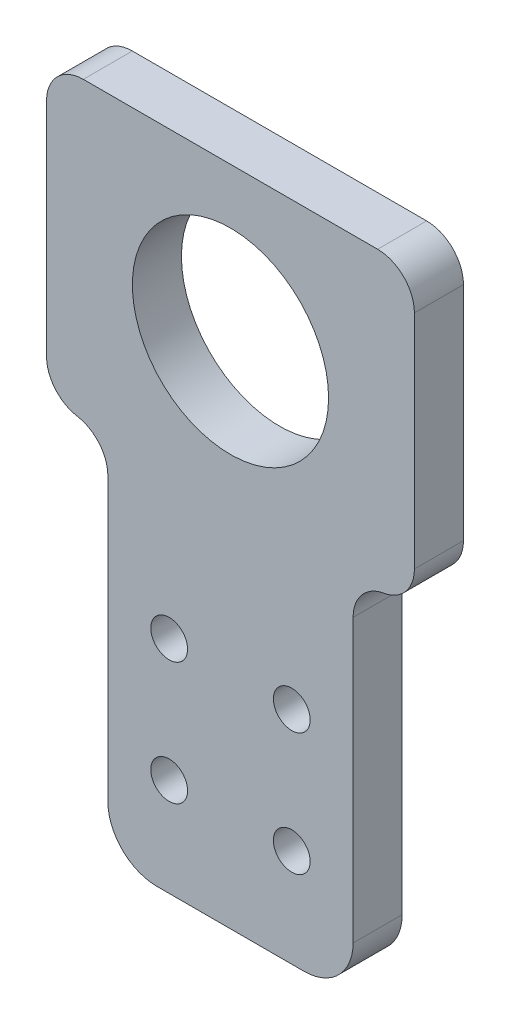
from build123d import *

# Parameters (mm, degrees)
SKETCH_1_W          = 20
SKETCH_1_H          = 30
SKETCH_1_R          = 1.5
EXTRUDE_1_DEPTH     = 4
SKETCH_2_W          = 30
SKETCH_2_H          = 4
EXTRUDE_2_DEPTH     = 24
FILLET_1_R          = 3
SKETCH_3_R          = 8
CUT_EXTRUDE_1_DEPTH = 24
FILLET_2_R          = 3
FILLET_3_R          = 4
FILLET_4_R          = 4


with BuildPart() as part:
    # 草图1 → 凸台-拉伸1 (new body)
    with BuildSketch(Plane.XY):
        Rectangle(SKETCH_1_W, SKETCH_1_H)
        with Locations((-5, 3)):
            Circle(SKETCH_1_R, mode=Mode.SUBTRACT)
        with Locations((5, 3)):
            Circle(SKETCH_1_R, mode=Mode.SUBTRACT)
        with Locations((-5, -7)):
            Circle(SKETCH_1_R, mode=Mode.SUBTRACT)
        with Locations((5, -7)):
            Circle(SKETCH_1_R, mode=Mode.SUBTRACT)
    extrude(amount=EXTRUDE_1_DEPTH)

    # 草图2 → 凸台-拉伸2 (add)
    with BuildSketch(Plane(origin=(0, 15, 0), x_dir=(1, 0, 0), z_dir=(0, 1, 0))):
        with Locations((0, -2)):
            Rectangle(SKETCH_2_W, SKETCH_2_H)
    extrude(amount=EXTRUDE_2_DEPTH)

    # 圆角1
    fillet_1_edges = [part.edges().sort_by_distance(p)[0] for p in [
        (-10, 15, 2),
        (10, 15, 2),
    ]]
    fillet(fillet_1_edges, radius=FILLET_1_R)

    # 草图3 → 切除-拉伸1 (cut)
    with BuildSketch(Plane.XY.offset(4)):
        with Locations((0, 26.5)):
            Circle(SKETCH_3_R)
    extrude(amount=-CUT_EXTRUDE_1_DEPTH, mode=Mode.SUBTRACT)

    # 圆角2
    fillet_2_edges = [part.edges().sort_by_distance(p)[0] for p in [
        (15, 15, 2),
        (15, 39, 2),
        (-15, 39, 2),
        (-15, 15, 2),
    ]]
    fillet(fillet_2_edges, radius=FILLET_2_R)

    # 圆角3
    fillet_3_edges = [part.edges().sort_by_distance(p)[0] for p in [
        (-10, -15, 2),
    ]]
    fillet(fillet_3_edges, radius=FILLET_3_R)

    # 圆角4
    fillet_4_edges = [part.edges().sort_by_distance(p)[0] for p in [
        (10, -15, 2),
    ]]
    fillet(fillet_4_edges, radius=FILLET_4_R)


solid = part.part
